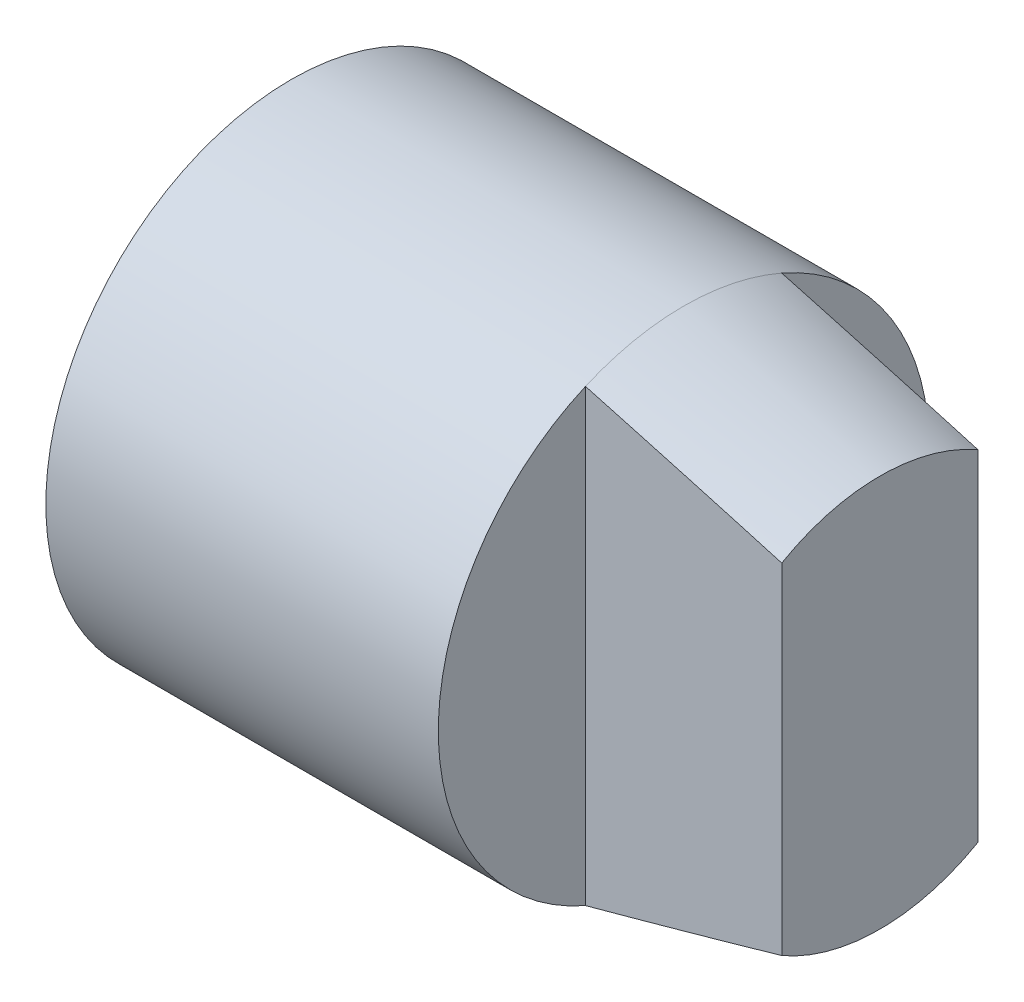
from build123d import *

# Parameters (mm, degrees)
CUT_EXTRUDE1_DEPTH = 4


with BuildPart() as part:
    # Sketch1 → Revolve1 (revolve)
    with BuildSketch(Plane.XY):
        Polygon((0, 0), (0, 5), (8, 5), (12, 4), (12, 0), align=None)
    revolve(axis=Axis((12, 0, 0), (-1, 0, 0)))

    # Sketch2 → Cut-Extrude1 (cut)
    with BuildSketch(Plane(origin=(12, 0, 0), x_dir=(0, 0, -1), z_dir=(1, 0, 0))):
        with BuildLine():
            Line((-2, -3.464101615), (-2, 3.464101615))
            ThreePointArc((-2, 3.464101615), (-4, 0), (-2, -3.464101615))
        make_face()
        with BuildLine():
            Line((-2, 3.464101615), (-2, 4.582575695))
            ThreePointArc((-2, 4.582575695), (-5, 0), (-2, -4.582575695))
            Line((-2, -4.582575695), (-2, -3.464101615))
            ThreePointArc((-2, -3.464101615), (-4, 0), (-2, 3.464101615))
        make_face()
        with BuildLine():
            ThreePointArc((4, 0), (3.464101615, 2), (2, 3.464101615))
            Line((2, 3.464101615), (2, -3.464101615))
            ThreePointArc((2, -3.464101615), (3.464101615, -2), (4, 0))
        make_face()
        with BuildLine():
            ThreePointArc((5, 0), (4.183300133, 2.738612788), (2, 4.582575695))
            Line((2, 4.582575695), (2, 3.464101615))
            ThreePointArc((2, 3.464101615), (3.464101615, 2), (4, 0))
            ThreePointArc((4, 0), (3.464101615, -2), (2, -3.464101615))
            Line((2, -3.464101615), (2, -4.582575695))
            ThreePointArc((2, -4.582575695), (4.183300133, -2.738612788), (5, 0))
        make_face()
    extrude(amount=-CUT_EXTRUDE1_DEPTH, mode=Mode.SUBTRACT)


solid = part.part
